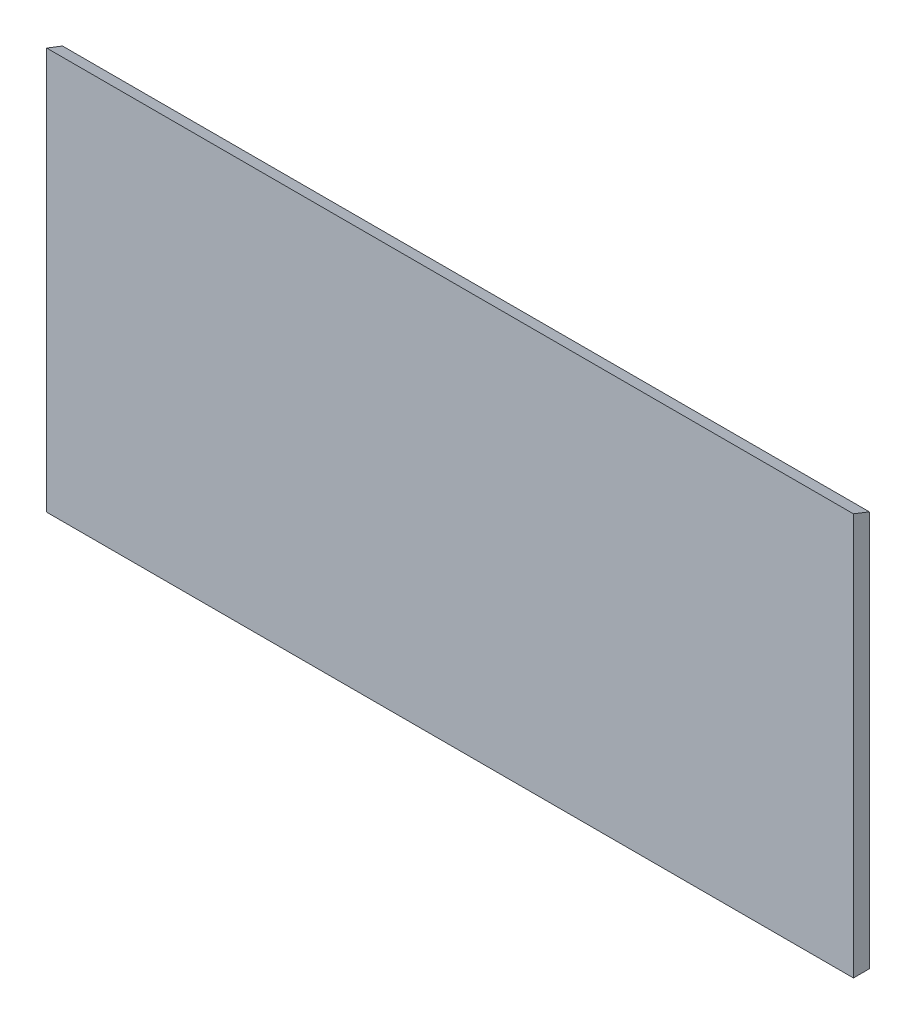
from build123d import *

# Parameters (mm, degrees)
SKETCH1_W           = 1700
SKETCH1_H           = 834
BOSS_EXTRUDE1_DEPTH = 33.45
BOSS_EXTRUDE2_DEPTH = 1700


with BuildPart() as part:
    # Sketch1 → Boss-Extrude1 (new body)
    with BuildSketch(Plane.XY):
        Rectangle(SKETCH1_W, SKETCH1_H)
    extrude(amount=BOSS_EXTRUDE1_DEPTH)

    # Sketch2 → Boss-Extrude2 (add)
    with BuildSketch(Plane(origin=(850, 0, 0), x_dir=(0, 0, -1), z_dir=(1, 0, 0))):
        Polygon((-33.45, 417), (-33.45, 430), (0, 417), align=None)
    extrude(amount=-BOSS_EXTRUDE2_DEPTH)


solid = part.part
